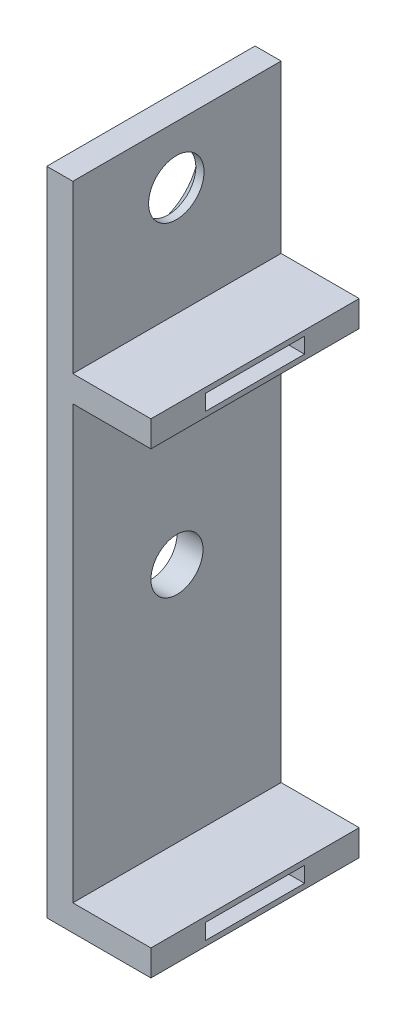
from build123d import *

# Parameters (mm, degrees)
BOSS_EXTRUDE1_DEPTH             = 10.16
SKETCH6_W                       = 10.16
SKETCH6_H                       = 1.27
BOSS_EXTRUDE3_DEPTH             = 3.81
SKETCH8_W                       = 4.826
SKETCH8_H                       = 0.762
CUT_EXTRUDE1_DEPTH              = 2.2352
SKETCH5_W                       = 4.826
SKETCH5_H                       = 0.762
CUT_EXTRUDE2_DEPTH              = 2.2352
SKETCH17_R                      = 1.27
CUT_EXTRUDE3_DEPTH              = 2.54
F_6_32_TAPPED_HOLE1_D           = 2.7051
F_6_32_TAPPED_HOLE1_DEPTH       = 9.398
F_6_32_TAPPED_HOLE1_CSINK_D     = 4.7752
F_6_32_TAPPED_HOLE1_CSINK_ANGLE = 100
F_6_32_TAPPED_HOLE1_TIP         = 0.81269403


with BuildPart() as part:
    # Sketch1 → Boss-Extrude1 (new body)
    with BuildSketch(Plane.XY):
        Polygon((-22.483233333, 11.63955), (-22.483233333, -18.84045), (-18.673233333, -18.84045), (-18.673233333, -20.11045), (-23.753233333, -20.11045), (-23.753233333, 11.63955), align=None)
    extrude(amount=BOSS_EXTRUDE1_DEPTH)

    # Sketch6 → Boss-Extrude3 (add)
    with BuildSketch(Plane(origin=(-22.483233333, 0, 0), x_dir=(0, 0, -1), z_dir=(1, 0, 0))):
        with Locations((-5.08, 2.87655)):
            Rectangle(SKETCH6_W, SKETCH6_H)
    extrude(amount=BOSS_EXTRUDE3_DEPTH)

    # Sketch8 → Cut-Extrude1 (cut)
    with BuildSketch(Plane(origin=(-18.673233333, 0, 0), x_dir=(0, 0, -1), z_dir=(1, 0, 0))):
        with Locations((-5.08, 2.87655)):
            Rectangle(SKETCH8_W, SKETCH8_H)
    extrude(amount=-CUT_EXTRUDE1_DEPTH, mode=Mode.SUBTRACT)

    # Sketch5 → Cut-Extrude2 (cut)
    with BuildSketch(Plane(origin=(-18.673233333, 0, 0), x_dir=(0, 0, -1), z_dir=(1, 0, 0))):
        with Locations((-5.08, -19.47545)):
            Rectangle(SKETCH5_W, SKETCH5_H)
    extrude(amount=-CUT_EXTRUDE2_DEPTH, mode=Mode.SUBTRACT)

    # Sketch17 → Cut-Extrude3 (cut)
    with BuildSketch(Plane(origin=(-22.483233333, 0, 0), x_dir=(0, 0, -1), z_dir=(1, 0, 0))):
        with Locations((-5.08, -7.084396388)):
            Circle(SKETCH17_R)
    extrude(amount=-CUT_EXTRUDE3_DEPTH, mode=Mode.SUBTRACT)

    # #6-32 Tapped Hole1
    with Locations(Plane.ZY.offset(23.753233333)):
        with Locations((5.111682079, 8.84555)):
            CounterSinkHole(F_6_32_TAPPED_HOLE1_D / 2, F_6_32_TAPPED_HOLE1_CSINK_D / 2, depth=F_6_32_TAPPED_HOLE1_DEPTH, counter_sink_angle=F_6_32_TAPPED_HOLE1_CSINK_ANGLE)
            with Locations((0, 0, -(F_6_32_TAPPED_HOLE1_DEPTH + F_6_32_TAPPED_HOLE1_TIP / 2))):  # 118° drill point
                Cone(0, F_6_32_TAPPED_HOLE1_D / 2, F_6_32_TAPPED_HOLE1_TIP, mode=Mode.SUBTRACT)


solid = part.part
